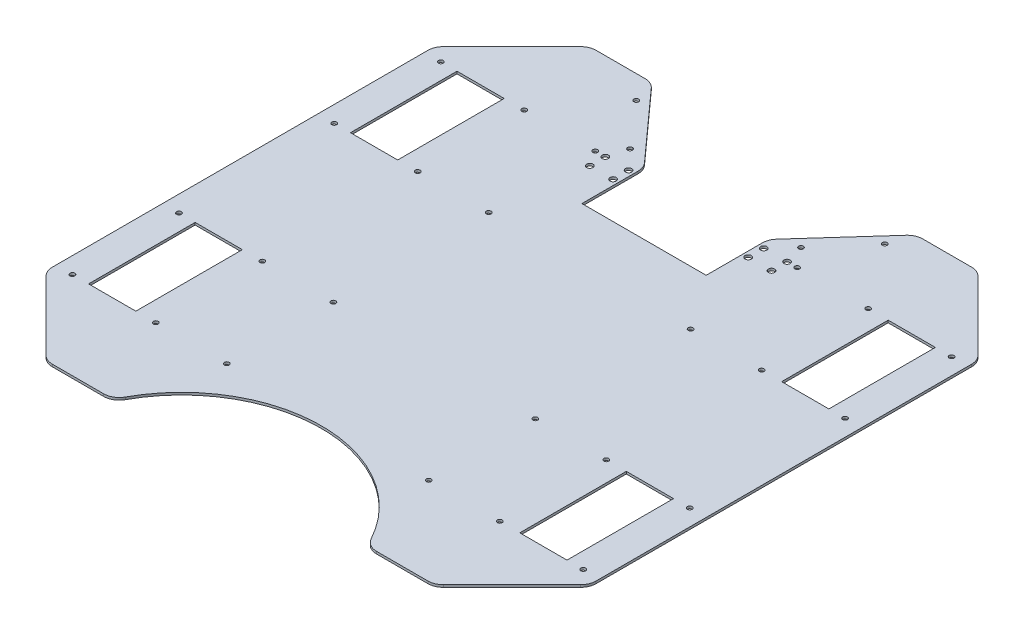
from build123d import *

# Parameters (mm, degrees)
SKETCH_1_R          = 1.55
SKETCH_1_W          = 30.4
SKETCH_1_H          = 68.58
EXTRUDE_1_DEPTH     = 1.5
FILLET_1_R          = 10
FILLET_2_R          = 10
FILLET_3_R          = 10
SKETCH_1_5_R        = 2
CUT_EXTRUDE_3_DEPTH = 10


with BuildPart() as part:
    # 草图1 → 凸台-拉伸1 (new body)
    with BuildSketch(Plane(origin=(0, 0, 0), x_dir=(1, 0, 0), z_dir=(0, 1, 0))):
        with BuildLine():
            Line((-125, 175), (-175, 125))
            Line((-175, 125), (-175, -125))
            Line((-175, -125), (-125, -175))
            Line((-125, -175), (-81.710313025, -175))
            ThreePointArc((-81.710313025, -175), (0, -122.728301649), (81.710313025, -175))
            Line((81.710313025, -175), (125, -175))
            Line((125, -175), (175, -125))
            Line((175, -125), (175, 125))
            Line((175, 125), (125, 175))
            Line((125, 175), (85, 175))
            Line((85, 175), (40, 125))
            Line((40, 125), (40, 85))
            Line((40, 85), (-40, 85))
            Line((-40, 85), (-40, 125))
            Line((-40, 125), (-85, 175))
            Line((-85, 175), (-125, 175))
        make_face()
        with Locations((-55, 131)):
            Circle(SKETCH_1_R, mode=Mode.SUBTRACT)
        with Locations((-80, 160)):
            Circle(SKETCH_1_R, mode=Mode.SUBTRACT)
        with Locations((55, 131)):
            Circle(SKETCH_1_R, mode=Mode.SUBTRACT)
        with Locations((80, 160)):
            Circle(SKETCH_1_R, mode=Mode.SUBTRACT)
        with Locations((-65, 118.58)):
            Circle(SKETCH_1_R, mode=Mode.SUBTRACT)
        with Locations((-65, 50)):
            Circle(SKETCH_1_R, mode=Mode.SUBTRACT)
        with Locations((-110.72, 50)):
            Circle(SKETCH_1_R, mode=Mode.SUBTRACT)
        with Locations((-110.72, 118.58)):
            Circle(SKETCH_1_R, mode=Mode.SUBTRACT)
        with Locations((-164.434, 118.58)):
            Circle(SKETCH_1_R, mode=Mode.SUBTRACT)
        with Locations((-164.434, 50)):
            Circle(SKETCH_1_R, mode=Mode.SUBTRACT)
        with Locations((-65, -118.58)):
            Circle(SKETCH_1_R, mode=Mode.SUBTRACT)
        with Locations((-65, -50)):
            Circle(SKETCH_1_R, mode=Mode.SUBTRACT)
        with Locations((-110.72, -50)):
            Circle(SKETCH_1_R, mode=Mode.SUBTRACT)
        with Locations((-110.72, -118.58)):
            Circle(SKETCH_1_R, mode=Mode.SUBTRACT)
        with Locations((-164.434, -50)):
            Circle(SKETCH_1_R, mode=Mode.SUBTRACT)
        with Locations((-164.434, -118.58)):
            Circle(SKETCH_1_R, mode=Mode.SUBTRACT)
        with Locations((65, 50)):
            Circle(SKETCH_1_R, mode=Mode.SUBTRACT)
        with Locations((110.72, 50)):
            Circle(SKETCH_1_R, mode=Mode.SUBTRACT)
        with Locations((110.72, 118.58)):
            Circle(SKETCH_1_R, mode=Mode.SUBTRACT)
        with Locations((65, 118.58)):
            Circle(SKETCH_1_R, mode=Mode.SUBTRACT)
        with Locations((164.434, 118.58)):
            Circle(SKETCH_1_R, mode=Mode.SUBTRACT)
        with Locations((164.434, 50)):
            Circle(SKETCH_1_R, mode=Mode.SUBTRACT)
        with Locations((164.434, -118.58)):
            Circle(SKETCH_1_R, mode=Mode.SUBTRACT)
        with Locations((164.434, -50)):
            Circle(SKETCH_1_R, mode=Mode.SUBTRACT)
        with Locations((110.72, -50)):
            Circle(SKETCH_1_R, mode=Mode.SUBTRACT)
        with Locations((110.72, -118.58)):
            Circle(SKETCH_1_R, mode=Mode.SUBTRACT)
        with Locations((65, -118.58)):
            Circle(SKETCH_1_R, mode=Mode.SUBTRACT)
        with Locations((65, -50)):
            Circle(SKETCH_1_R, mode=Mode.SUBTRACT)
        with Locations((-138.794, 84.29)):
            Rectangle(SKETCH_1_W, SKETCH_1_H, mode=Mode.SUBTRACT)
        with Locations((138.794, 84.29)):
            Rectangle(SKETCH_1_W, SKETCH_1_H, mode=Mode.SUBTRACT)
        with Locations((-138.794, -84.29)):
            Rectangle(SKETCH_1_W, SKETCH_1_H, mode=Mode.SUBTRACT)
        with Locations((138.794, -84.29)):
            Rectangle(SKETCH_1_W, SKETCH_1_H, mode=Mode.SUBTRACT)
    extrude(amount=EXTRUDE_1_DEPTH)

    # 圆角1
    fillet_1_edges = [part.edges().sort_by_distance(p)[0] for p in [
        (-40, 0.75, -125),
    ]]
    fillet(fillet_1_edges, radius=FILLET_1_R)

    # 圆角2
    fillet_2_edges = [part.edges().sort_by_distance(p)[0] for p in [
        (40, 0.75, -125),
    ]]
    fillet(fillet_2_edges, radius=FILLET_2_R)

    # 圆角3
    fillet_3_edges = [part.edges().sort_by_distance(p)[0] for p in [
        (-85, 0.75, -175),
        (85, 0.75, -175),
        (125, 0.75, -175),
        (175, 0.75, -125),
        (175, 0.75, 125),
        (125, 0.75, 175),
        (81.710313025, 0.75, 175),
        (-81.710313025, 0.75, 175),
        (-125, 0.75, 175),
        (-175, 0.75, 125),
        (-175, 0.75, -125),
        (-125, 0.75, -175),
    ]]
    fillet(fillet_3_edges, radius=FILLET_3_R)

    # 草图1<5> → 切除-拉伸3 (cut)
    with BuildSketch(Plane(origin=(0, 0, 0), x_dir=(1, 0, 0), z_dir=(0, 1, 0))):
        with Locations((-58.5, 118.58)):
            Circle(SKETCH_1_5_R)
        with Locations((-43.5, 118.58)):
            Circle(SKETCH_1_5_R)
        with Locations((-58.5, 108.58)):
            Circle(SKETCH_1_5_R)
        with Locations((-43.5, 108.58)):
            Circle(SKETCH_1_5_R)
        with Locations((43.5, 108.58)):
            Circle(SKETCH_1_5_R)
        with Locations((58.5, 108.58)):
            Circle(SKETCH_1_5_R)
        with Locations((43.5, 118.58)):
            Circle(SKETCH_1_5_R)
        with Locations((58.5, 118.58)):
            Circle(SKETCH_1_5_R)
    extrude(amount=CUT_EXTRUDE_3_DEPTH, mode=Mode.SUBTRACT)


solid = part.part
